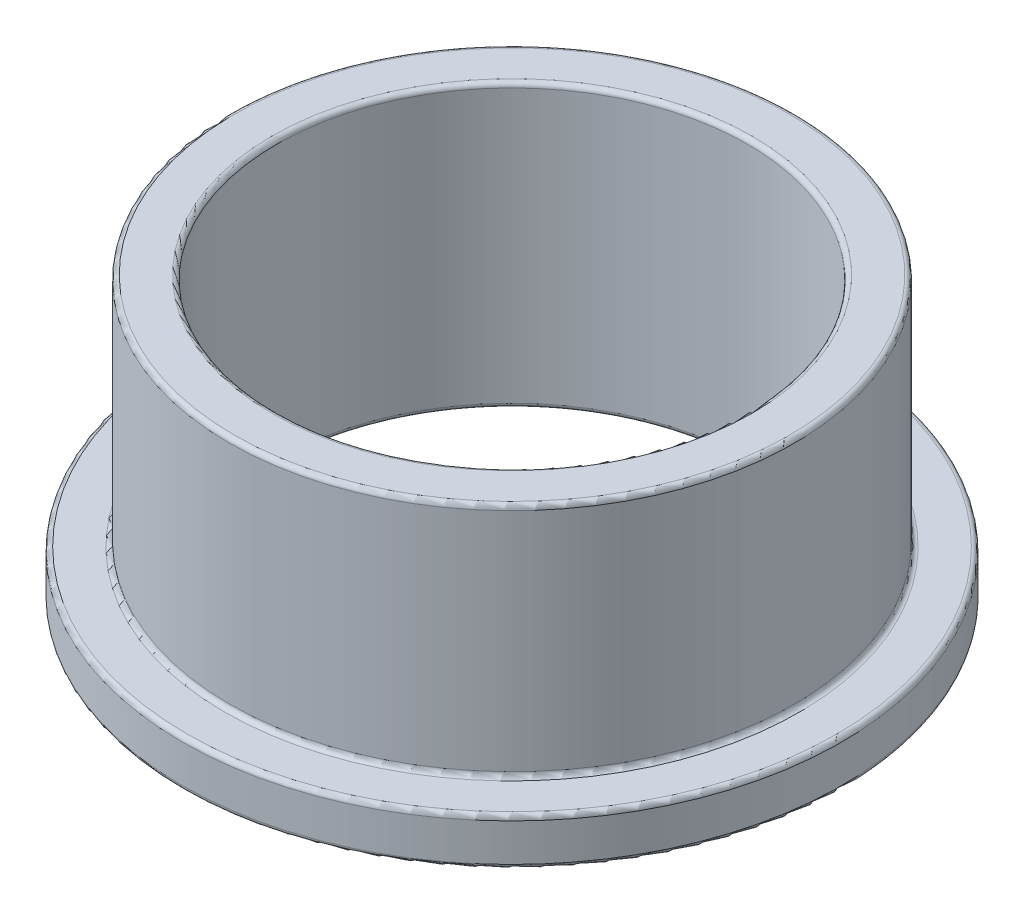
from build123d import *

# Parameters (mm, degrees)
SKETCH3_R           = 6
SKETCH3_R_2         = 5
BOSS_EXTRUDE1_DEPTH = 6
SKETCH4_R           = 7
SKETCH4_R_2         = 6
BOSS_EXTRUDE2_DEPTH = 1
FILLET1_R           = 0.1


with BuildPart() as part:
    # Sketch3 → Boss-Extrude1 (new body)
    with BuildSketch(Plane(origin=(0, 0, 0), x_dir=(1, 0, 0), z_dir=(0, 1, 0))):
        Circle(SKETCH3_R)
        Circle(SKETCH3_R_2, mode=Mode.SUBTRACT)
    extrude(amount=BOSS_EXTRUDE1_DEPTH)

    # Sketch4 → Boss-Extrude2 (add)
    with BuildSketch(Plane(origin=(0, 0, 0), x_dir=(1, 0, 0), z_dir=(0, 1, 0))):
        Circle(SKETCH4_R)
        Circle(SKETCH4_R_2, mode=Mode.SUBTRACT)
    extrude(amount=BOSS_EXTRUDE2_DEPTH)

    # Fillet1
    fillet1_edges = [part.edges().sort_by_distance(p)[0] for p in [
        (-7, 0, 0),
        (-6, 1, 0),
        (-6, 6, 0),
        (-5, 0, 0),
        (-5, 6, 0),
        (-7, 1, 0),
    ]]
    fillet(fillet1_edges, radius=FILLET1_R)


solid = part.part
